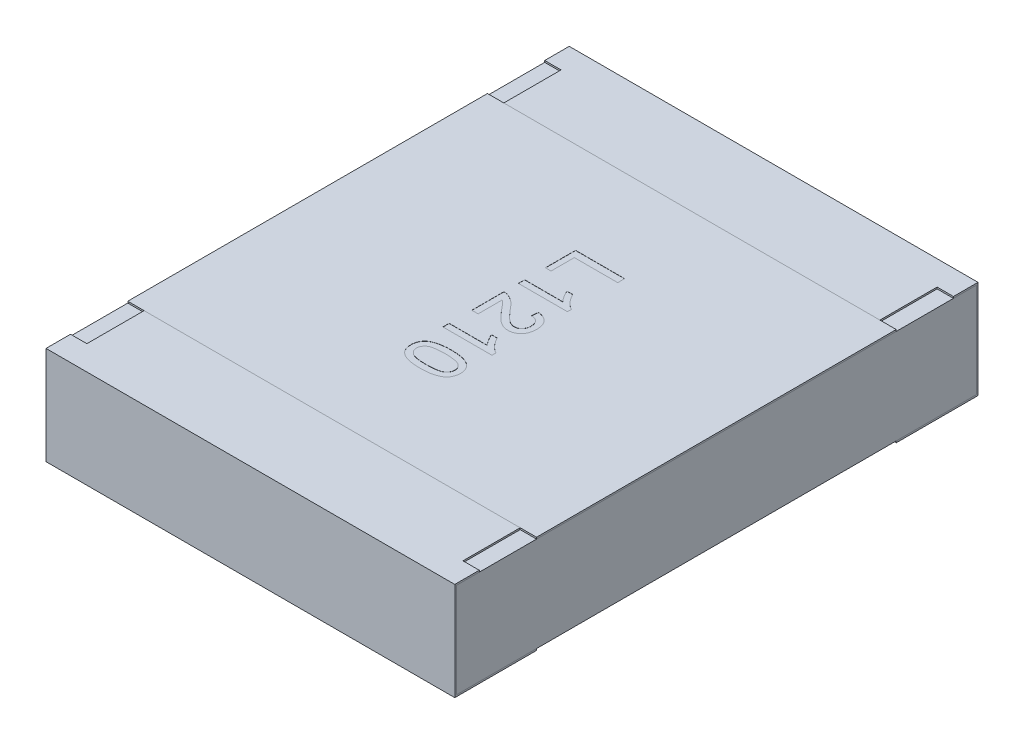
from build123d import *

# Parameters (mm, degrees)
BOSS_EXTRUDE2_DEPTH   = 1.25
BOSS_EXTRUDE2_2_DEPTH = 1.25
BOSS_EXTRUDE3_START   = -1.25
SKETCH5_W             = 3.18
SKETCH5_H             = 0.58
BOSS_EXTRUDE3_DEPTH   = 2.5
SKETCH6_W             = 0.1
SKETCH6_H             = 0.35
CUT_EXTRUDE1_DEPTH    = 0.01
SKETCH7_W             = 2.5
SKETCH7_H             = 2.2
BOSS_EXTRUDE4_DEPTH   = 0.01
TEXT1210_DEPTH        = 0.001


with BuildPart() as part:
    # Sketch4 → Boss-Extrude2 (new body, symmetric)
    with BuildSketch(Plane(origin=(0, 0, 0), x_dir=(0, 0, -1), z_dir=(1, 0, 0))):
        Polygon((-1.6, 0.3), (-1.6, -0.3), (-1.1, -0.3), (-1.1, -0.29), (-1.59, -0.29), (-1.59, 0.29), (-1.1, 0.29), (-1.1, 0.3), align=None)
    extrude(amount=BOSS_EXTRUDE2_DEPTH, both=True)


with BuildPart() as body_2:
    # Sketch4 → Boss-Extrude2 2 (new body, symmetric)
    with BuildSketch(Plane(origin=(0, 0, 0), x_dir=(0, 0, -1), z_dir=(1, 0, 0))):
        Polygon((1.1, 0.3), (1.6, 0.3), (1.6, -0.3), (1.1, -0.3), (1.1, -0.29), (1.59, -0.29), (1.59, 0.29), (1.1, 0.29), align=None)
    extrude(amount=BOSS_EXTRUDE2_2_DEPTH, both=True)


with BuildPart() as body_3:
    # Sketch5 → Boss-Extrude3 (new body)
    with BuildSketch(Plane(origin=(0, 0, 0), x_dir=(0, 0, -1), z_dir=(1, 0, 0)).offset(BOSS_EXTRUDE3_START)):
        Rectangle(SKETCH5_W, SKETCH5_H)
    extrude(amount=BOSS_EXTRUDE3_DEPTH)


with BuildPart() as cut_extrude1_tool:
    # Sketch6 → Cut-Extrude1 (new body)
    with BuildSketch(Plane(origin=(0, 0.3, 0), x_dir=(1, 0, 0), z_dir=(0, 1, 0))):
        with Locations((-1.2, 1.275)):
            Rectangle(SKETCH6_W, SKETCH6_H)
        with Locations((1.2, 1.275)):
            Rectangle(SKETCH6_W, SKETCH6_H)
        with Locations((1.2, -1.275)):
            Rectangle(SKETCH6_W, SKETCH6_H)
        with Locations((-1.2, -1.275)):
            Rectangle(SKETCH6_W, SKETCH6_H)
    extrude(amount=-CUT_EXTRUDE1_DEPTH)


with BuildPart() as part_1:
    add(part.part)

    # Cut-Extrude1: cut by cut_extrude1_tool
    add(cut_extrude1_tool.part, mode=Mode.SUBTRACT)


with BuildPart() as body_2_1:
    add(body_2.part)

    # Cut-Extrude1: cut by cut_extrude1_tool
    add(cut_extrude1_tool.part, mode=Mode.SUBTRACT)


with BuildPart() as body_4:
    # Sketch7 → Boss-Extrude4 (new body)
    with BuildSketch(Plane(origin=(0, 0.29, 0), x_dir=(1, 0, 0), z_dir=(0, 1, 0))):
        Rectangle(SKETCH7_W, SKETCH7_H)
    extrude(amount=BOSS_EXTRUDE4_DEPTH)

    # Sketch13 → TEXT1210 (cut)
    with BuildSketch(Plane(origin=(0, 0.3, 0), x_dir=(1, 0, 0), z_dir=(0, 1, 0))):
        Polygon((-0.15, 0.53890045), (0.15, 0.53890045), (0.15, 0.496592758), (-0.115384615, 0.496592758), (-0.115384615, 0.354285066), (-0.15, 0.354285066), align=None)
        with BuildLine():
            Line((-0.15, 0.18890045), (-0.15, 0.227361989))
            Line((-0.15, 0.227361989), (0.083774038, 0.227361989))
            add(Edge.make_bspline(
                [(0.083774038, 0.227361989), (0.081638509, 0.229576734), (0.077200045, 0.234179841), (0.070914564, 0.241958301), (0.064571645, 0.250638154), (0.058389404, 0.260075408), (0.052683492, 0.269769346), (0.047476916, 0.27910891), (0.043093554, 0.287963651), (0.040694469, 0.293794722), (0.039543269, 0.296592758)],
                knots=[0, 0, 0, 0, 9.226e-06, 1.9175e-05, 2.9969e-05, 4.147e-05, 5.3003e-05, 6.3709e-05, 7.3546e-05, 8.262e-05, 8.262e-05, 8.262e-05, 8.262e-05], degree=3))
            Line((0.039543269, 0.296592758), (0.075, 0.296592758))
            add(Edge.make_bspline(
                [(0.075, 0.296592758), (0.077475162, 0.291786638), (0.082353558, 0.282314059), (0.09077922, 0.268931354), (0.099912985, 0.256437159), (0.10975283, 0.245038303), (0.119810917, 0.234819955), (0.129959923, 0.226208805), (0.139827828, 0.219003542), (0.146709597, 0.215388526), (0.15, 0.213660066)],
                knots=[0, 0, 0, 0, 1.6212e-05, 3.1953e-05, 4.7386e-05, 6.26e-05, 7.7091e-05, 9.0349e-05, 0.000102505, 0.000113642, 0.000113642, 0.000113642, 0.000113642], degree=3))
            Line((0.15, 0.213660066), (0.15, 0.18890045))
            Line((0.15, 0.18890045), (-0.15, 0.18890045))
        make_face()
        with BuildLine():
            Line((-0.111538462, -0.095714934), (-0.15, -0.095714934))
            Line((-0.15, -0.095714934), (-0.15, 0.100438912))
            add(Edge.make_bspline(
                [(-0.15, 0.100438912), (-0.147714123, 0.100442928), (-0.14315003, 0.100450946), (-0.136400026, 0.099678628), (-0.129739566, 0.098469023), (-0.125468478, 0.097101323), (-0.123317308, 0.096412469)],
                knots=[0, 0, 0, 0, 6.852e-06, 1.3681e-05, 2.0352e-05, 2.7121e-05, 2.7121e-05, 2.7121e-05, 2.7121e-05], degree=3))
            add(Edge.make_bspline(
                [(-0.123317308, 0.096412469), (-0.119803316, 0.095138453), (-0.112648251, 0.092544345), (-0.102300861, 0.087308751), (-0.092077121, 0.081048211), (-0.083693742, 0.075056739), (-0.077044802, 0.069538585), (-0.071780052, 0.064988128), (-0.066458477, 0.059862129), (-0.06098519, 0.054254035), (-0.055359875, 0.048197879), (-0.049556317, 0.041693897), (-0.043684824, 0.034662817), (-0.039792869, 0.02975449), (-0.037800481, 0.027241796)],
                knots=[0, 0, 0, 0, 1.1205e-05, 2.2816e-05, 3.4709e-05, 4.7152e-05, 5.3684e-05, 6.0627e-05, 6.8023e-05, 7.5842e-05, 8.4134e-05, 9.2818e-05, 0.00010199, 0.00011161, 0.00011161, 0.00011161, 0.00011161], degree=3))
            add(Edge.make_bspline(
                [(-0.037800481, 0.027241796), (-0.034551471, 0.023381665), (-0.028295295, 0.015948736), (-0.019011711, 0.005452276), (-0.010391377, -0.004134531), (-0.002283205, -0.012659028), (0.005234162, -0.020190934), (0.012143692, -0.026747935), (0.018423822, -0.03238645), (0.024301865, -0.037037644), (0.029852373, -0.040961998), (0.035266551, -0.044287542), (0.040638972, -0.047058942), (0.045952637, -0.049367147), (0.05123027, -0.051192741), (0.056487246, -0.052437143), (0.061671403, -0.053281053), (0.065120999, -0.053365487), (0.066826923, -0.053407242)],
                knots=[0, 0, 0, 0, 1.5136e-05, 2.9145e-05, 4.2036e-05, 5.3811e-05, 6.4435e-05, 7.3957e-05, 8.2386e-05, 8.9745e-05, 9.643e-05, 0.000102769, 0.00010879, 0.00011455, 0.000120137, 0.000125516, 0.000130743, 0.000135857, 0.000135857, 0.000135857, 0.000135857], degree=3))
            add(Edge.make_bspline(
                [(0.066826923, -0.053407242), (0.068512943, -0.053365482), (0.071820821, -0.053283551), (0.076661881, -0.052506195), (0.081323937, -0.051424053), (0.085723062, -0.049674559), (0.089989535, -0.047592135), (0.093988521, -0.044920918), (0.097819766, -0.041830895), (0.101381944, -0.038292978), (0.104724786, -0.034429128), (0.107500012, -0.030110376), (0.110020859, -0.025610863), (0.111988045, -0.020781877), (0.113504097, -0.015666428), (0.114560258, -0.01027272), (0.115243078, -0.004586351), (0.115336721, -0.000704927), (0.115384615, 0.001280258)],
                knots=[0, 0, 0, 0, 5.054e-06, 9.915e-06, 1.4681e-05, 1.938e-05, 2.4083e-05, 2.89e-05, 3.3772e-05, 3.8829e-05, 4.3946e-05, 4.9063e-05, 5.4199e-05, 5.94e-05, 6.4667e-05, 7.0183e-05, 7.587e-05, 8.1825e-05, 8.1825e-05, 8.1825e-05, 8.1825e-05], degree=3))
            add(Edge.make_bspline(
                [(0.115384615, 0.001280258), (0.115336639, 0.003365522), (0.115242746, 0.007446536), (0.114561705, 0.013412531), (0.113515033, 0.019073785), (0.111941815, 0.024410106), (0.109882187, 0.029410823), (0.10742732, 0.034111385), (0.104518024, 0.03849382), (0.101139001, 0.042487997), (0.097458268, 0.046187848), (0.093296561, 0.049313409), (0.088872885, 0.052045577), (0.084046797, 0.05420091), (0.078924308, 0.055958652), (0.073429376, 0.057227398), (0.067585566, 0.057920825), (0.063583419, 0.05806007), (0.061538462, 0.058131219)],
                knots=[0, 0, 0, 0, 6.255e-06, 1.2241e-05, 1.7992e-05, 2.3507e-05, 2.8897e-05, 3.4193e-05, 3.9393e-05, 4.4641e-05, 4.9868e-05, 5.5012e-05, 6.0217e-05, 6.5434e-05, 7.0832e-05, 7.6444e-05, 8.2318e-05, 8.8455e-05, 8.8455e-05, 8.8455e-05, 8.8455e-05], degree=3))
            Line((0.061538462, 0.058131219), (0.065384615, 0.096592758))
            add(Edge.make_bspline(
                [(0.065384615, 0.096592758), (0.068736662, 0.096199283), (0.07525778, 0.095433812), (0.084702032, 0.093526357), (0.093489714, 0.090851287), (0.101734943, 0.087640776), (0.109336857, 0.083645414), (0.116323186, 0.079013557), (0.122725854, 0.073748815), (0.12839596, 0.067759508), (0.133571363, 0.061274876), (0.137925688, 0.054134056), (0.141698648, 0.046502706), (0.144749435, 0.038326511), (0.147087025, 0.029608682), (0.148758415, 0.020362795), (0.149789925, 0.010578384), (0.149928976, 0.00386696), (0.15, 0.000438912)],
                knots=[0, 0, 0, 0, 1.0123e-05, 1.9693e-05, 2.8857e-05, 3.7651e-05, 4.6199e-05, 5.4566e-05, 6.276e-05, 7.1006e-05, 7.9266e-05, 8.7604e-05, 9.6043e-05, 0.000104772, 0.000113738, 0.000123085, 0.000132934, 0.000143217, 0.000143217, 0.000143217, 0.000143217], degree=3))
            add(Edge.make_bspline(
                [(0.15, 0.000438912), (0.149940576, -0.003030142), (0.149824817, -0.00978788), (0.148641062, -0.019635171), (0.146795931, -0.028925684), (0.144229333, -0.037696602), (0.140839664, -0.045901328), (0.136757117, -0.053567953), (0.131911514, -0.0606722), (0.126324053, -0.067117627), (0.120221623, -0.072930045), (0.113705953, -0.078016298), (0.106829733, -0.082292372), (0.099612825, -0.085829272), (0.092008541, -0.088537508), (0.084045391, -0.090422257), (0.075742745, -0.091708806), (0.070077161, -0.091814747), (0.0671875, -0.091868781)],
                knots=[0, 0, 0, 0, 1.0403e-05, 2.0265e-05, 2.9705e-05, 3.8794e-05, 4.7633e-05, 5.6291e-05, 6.4808e-05, 7.3373e-05, 8.1833e-05, 9.0055e-05, 9.8126e-05, 0.000106082, 0.000114122, 0.000122285, 0.000130605, 0.000139266, 0.000139266, 0.000139266, 0.000139266], degree=3))
            add(Edge.make_bspline(
                [(0.0671875, -0.091868781), (0.064218398, -0.091787667), (0.05827364, -0.091625261), (0.049399233, -0.090309986), (0.040594357, -0.08819279), (0.03178904, -0.08525502), (0.02297561, -0.081166575), (0.013942435, -0.076131331), (0.004756402, -0.069837959), (-0.003111225, -0.063869709), (-0.009660413, -0.058250445), (-0.015062592, -0.053269642), (-0.020824791, -0.047508563), (-0.027059821, -0.041120412), (-0.033675497, -0.033974347), (-0.04077151, -0.026200588), (-0.048197577, -0.017644735), (-0.053269547, -0.011704156), (-0.055889423, -0.008635607)],
                knots=[0, 0, 0, 0, 8.904e-06, 1.7828e-05, 2.6851e-05, 3.6049e-05, 4.5623e-05, 5.5954e-05, 6.7039e-05, 7.8998e-05, 8.5562e-05, 9.292e-05, 0.000101036, 0.000110004, 0.000119698, 0.000130249, 0.000141579, 0.000153683, 0.000153683, 0.000153683, 0.000153683], degree=3))
            add(Edge.make_bspline(
                [(-0.055889423, -0.008635607), (-0.058028577, -0.00600791), (-0.062107615, -0.000997295), (-0.068021764, 0.006130704), (-0.073442596, 0.012517194), (-0.07820298, 0.01830303), (-0.082492694, 0.023292168), (-0.086224809, 0.027591619), (-0.089451821, 0.031158691), (-0.094402484, 0.036596509), (-0.10140021, 0.043536178), (-0.108253196, 0.048608326), (-0.111538462, 0.051039873)],
                knots=[0, 0, 0, 0, 1.0165e-05, 1.9383e-05, 2.7786e-05, 3.5295e-05, 4.1859e-05, 4.7524e-05, 5.2375e-05, 5.6288e-05, 6.9591e-05, 8.184e-05, 8.184e-05, 8.184e-05, 8.184e-05], degree=3))
            Line((-0.111538462, 0.051039873), (-0.111538462, -0.095714934))
        make_face()
        with BuildLine():
            Line((-0.15, -0.272638011), (-0.15, -0.234176473))
            Line((-0.15, -0.234176473), (0.083774038, -0.234176473))
            add(Edge.make_bspline(
                [(0.083774038, -0.234176473), (0.081638509, -0.231961727), (0.077200045, -0.227358621), (0.070914564, -0.21958016), (0.064571645, -0.210900308), (0.058389404, -0.201463054), (0.052683492, -0.191769115), (0.047476916, -0.182429552), (0.043093554, -0.17357481), (0.040694469, -0.167743739), (0.039543269, -0.164945704)],
                knots=[0, 0, 0, 0, 9.226e-06, 1.9175e-05, 2.9969e-05, 4.147e-05, 5.3003e-05, 6.3709e-05, 7.3546e-05, 8.262e-05, 8.262e-05, 8.262e-05, 8.262e-05], degree=3))
            Line((0.039543269, -0.164945704), (0.075, -0.164945704))
            add(Edge.make_bspline(
                [(0.075, -0.164945704), (0.077475162, -0.169751824), (0.082353558, -0.179224402), (0.09077922, -0.192607107), (0.099912985, -0.205101302), (0.10975283, -0.216500158), (0.119810917, -0.226718506), (0.129959923, -0.235329657), (0.139827828, -0.242534919), (0.146709597, -0.246149936), (0.15, -0.247878396)],
                knots=[0, 0, 0, 0, 1.6212e-05, 3.1953e-05, 4.7386e-05, 6.26e-05, 7.7091e-05, 9.0349e-05, 0.000102505, 0.000113642, 0.000113642, 0.000113642, 0.000113642], degree=3))
            Line((0.15, -0.247878396), (0.15, -0.272638011))
            Line((0.15, -0.272638011), (-0.15, -0.272638011))
        make_face()
        with BuildLine():
            add(Edge.make_bspline(
                [(-0.002043269, -0.368791857), (0.002244006, -0.368830608), (0.010640973, -0.368906503), (0.022927245, -0.369377254), (0.034595007, -0.37019915), (0.045634132, -0.371426007), (0.05606952, -0.372878857), (0.065886336, -0.374767497), (0.075106414, -0.376892738), (0.083720798, -0.379441782), (0.091801288, -0.382245278), (0.099342803, -0.385415635), (0.106300734, -0.389014065), (0.112864039, -0.392716086), (0.118725274, -0.397026184), (0.12425569, -0.401397143), (0.129139599, -0.406276003), (0.133536862, -0.411430723), (0.137415967, -0.416946734), (0.140763485, -0.422792352), (0.143719015, -0.42894575), (0.145943958, -0.435524024), (0.147757752, -0.44239066), (0.149092003, -0.4495985), (0.149878588, -0.45715549), (0.149959072, -0.46231963), (0.15, -0.464945704)],
                knots=[0, 0, 0, 0, 1.2862e-05, 2.5191e-05, 3.688e-05, 4.7943e-05, 5.8507e-05, 6.8478e-05, 7.7924e-05, 8.6881e-05, 9.5415e-05, 0.000103574, 0.000111395, 0.000118909, 0.000126147, 0.000133195, 0.000140037, 0.000146816, 0.000153502, 0.000160233, 0.000167008, 0.000173945, 0.000181029, 0.000188302, 0.000195914, 0.00020379, 0.00020379, 0.00020379, 0.00020379], degree=3))
            add(Edge.make_bspline(
                [(0.15, -0.464945704), (0.149886629, -0.468798426), (0.149663908, -0.476367254), (0.147850494, -0.487418957), (0.144740696, -0.49783), (0.140578188, -0.507598756), (0.135193656, -0.516513994), (0.128816305, -0.524574198), (0.121179131, -0.531453701), (0.11253276, -0.537379751), (0.102860028, -0.542461339), (0.092252026, -0.547007027), (0.080663785, -0.55108266), (0.070320072, -0.554065846), (0.061375886, -0.556157324), (0.053985027, -0.557430675), (0.046034731, -0.558606346), (0.03750596, -0.559439678), (0.028438575, -0.560287661), (0.018793038, -0.560706321), (0.008575899, -0.561025819), (0.001562812, -0.561074512), (-0.002043269, -0.56109955)],
                knots=[0, 0, 0, 0, 1.1554e-05, 2.2698e-05, 3.348e-05, 4.4085e-05, 5.4464e-05, 6.4638e-05, 7.4805e-05, 8.5173e-05, 9.6008e-05, 0.000107529, 0.00011977, 0.000132837, 0.000139806, 0.000147315, 0.000155329, 0.00016391, 0.000173019, 0.000182646, 0.000192867, 0.000203685, 0.000203685, 0.000203685, 0.000203685], degree=3))
            add(Edge.make_bspline(
                [(-0.002043269, -0.56109955), (-0.00631044, -0.561060292), (-0.014647199, -0.560983595), (-0.026834487, -0.560522423), (-0.03841587, -0.559661687), (-0.049405471, -0.558552503), (-0.059813481, -0.557059128), (-0.069614428, -0.55519258), (-0.078820333, -0.553036715), (-0.087440482, -0.550597058), (-0.095486737, -0.547758694), (-0.102997606, -0.544557395), (-0.110046684, -0.541124657), (-0.116502689, -0.537230998), (-0.122472492, -0.533084021), (-0.127974887, -0.528644981), (-0.132931669, -0.523821932), (-0.137314485, -0.518619096), (-0.141263346, -0.513142462), (-0.144641302, -0.507281652), (-0.147459366, -0.501050378), (-0.149814671, -0.494504175), (-0.151604655, -0.487599592), (-0.15293367, -0.480372606), (-0.153727476, -0.472776068), (-0.153806049, -0.467591837), (-0.153846154, -0.464945704)],
                knots=[0, 0, 0, 0, 1.2802e-05, 2.5011e-05, 3.658e-05, 4.7637e-05, 5.8141e-05, 6.8112e-05, 7.7558e-05, 8.6498e-05, 9.4975e-05, 0.000103135, 0.000110983, 0.000118475, 0.000125727, 0.000132776, 0.000139661, 0.00014644, 0.00015316, 0.000159891, 0.000166695, 0.000173652, 0.000180737, 0.000188068, 0.000195681, 0.000203617, 0.000203617, 0.000203617, 0.000203617], degree=3))
            add(Edge.make_bspline(
                [(-0.153846154, -0.464945704), (-0.153747192, -0.461476394), (-0.153554242, -0.454712195), (-0.152243272, -0.44483358), (-0.149935902, -0.435561974), (-0.146841394, -0.426819175), (-0.142702311, -0.418703454), (-0.137666308, -0.411176063), (-0.131850554, -0.404085743), (-0.127262057, -0.400004124), (-0.124939904, -0.397938492)],
                knots=[0, 0, 0, 0, 1.0408e-05, 2.0292e-05, 2.9825e-05, 3.9025e-05, 4.8056e-05, 5.7073e-05, 6.616e-05, 7.5471e-05, 7.5471e-05, 7.5471e-05, 7.5471e-05], degree=3))
            add(Edge.make_bspline(
                [(-0.124939904, -0.397938492), (-0.121510195, -0.395560902), (-0.11443799, -0.39065821), (-0.102379223, -0.384920033), (-0.089104214, -0.379801478), (-0.074352508, -0.375784351), (-0.058241513, -0.372637939), (-0.040739616, -0.370365444), (-0.021854376, -0.369079436), (-0.008796046, -0.368889881), (-0.002043269, -0.368791857)],
                knots=[0, 0, 0, 0, 1.2501e-05, 2.5778e-05, 3.993e-05, 5.5152e-05, 7.157e-05, 8.9147e-05, 0.000108063, 0.000128321, 0.000128321, 0.000128321, 0.000128321], degree=3))
        make_face()
        with BuildLine():
            add(Edge.make_bspline(
                [(-0.001923077, -0.407253396), (-0.007693168, -0.407291585), (-0.018738399, -0.407364688), (-0.034518417, -0.408128433), (-0.048754147, -0.40944319), (-0.061425879, -0.411181383), (-0.072550754, -0.413476503), (-0.082100422, -0.416358297), (-0.090189501, -0.419606764), (-0.096717734, -0.423626681), (-0.102039196, -0.428028046), (-0.106615825, -0.432572155), (-0.110505855, -0.437365914), (-0.113749347, -0.442378045), (-0.116205105, -0.447686315), (-0.117985045, -0.453232679), (-0.119009373, -0.459018343), (-0.119156549, -0.462958644), (-0.119230769, -0.464945704)],
                knots=[0, 0, 0, 0, 1.7309e-05, 3.3134e-05, 4.7378e-05, 6.0186e-05, 7.1489e-05, 8.1413e-05, 9.0085e-05, 9.7558e-05, 0.000104306, 0.000110765, 0.000116876, 0.000122794, 0.000128628, 0.000134368, 0.000140227, 0.000146187, 0.000146187, 0.000146187, 0.000146187], degree=3))
            add(Edge.make_bspline(
                [(-0.119230769, -0.464945704), (-0.119154928, -0.466932266), (-0.119004535, -0.47087158), (-0.118002795, -0.476670613), (-0.116131225, -0.482195397), (-0.11368414, -0.487495752), (-0.110514577, -0.492544313), (-0.106609854, -0.497314529), (-0.102035942, -0.501882574), (-0.096652628, -0.506264169), (-0.090094213, -0.510253459), (-0.082011723, -0.513562864), (-0.072445331, -0.516399747), (-0.061326124, -0.51870746), (-0.048674427, -0.520452824), (-0.03447818, -0.521759631), (-0.018718466, -0.522528488), (-0.007693194, -0.522600384), (-0.001923077, -0.522638011)],
                knots=[0, 0, 0, 0, 5.96e-06, 1.1819e-05, 1.7578e-05, 2.3412e-05, 2.9298e-05, 3.5408e-05, 4.1867e-05, 4.8662e-05, 5.6186e-05, 6.4803e-05, 7.4784e-05, 8.6088e-05, 9.8836e-05, 0.00011308, 0.000128845, 0.000146154, 0.000146154, 0.000146154, 0.000146154], degree=3))
            add(Edge.make_bspline(
                [(-0.001923077, -0.522638011), (0.003726983, -0.522601589), (0.014552285, -0.522531806), (0.030028294, -0.521743114), (0.044025103, -0.520507191), (0.056555506, -0.518816554), (0.067606248, -0.516569984), (0.077199767, -0.513844336), (0.085318952, -0.510598965), (0.09203502, -0.506732082), (0.097578912, -0.502444607), (0.102284051, -0.497889274), (0.106407321, -0.493154239), (0.109635927, -0.487968915), (0.11228385, -0.482553737), (0.114056455, -0.476792621), (0.1151941, -0.470759955), (0.115320181, -0.466633736), (0.115384615, -0.464525031)],
                knots=[0, 0, 0, 0, 1.6949e-05, 3.2473e-05, 4.6473e-05, 5.9094e-05, 7.0385e-05, 8.0274e-05, 8.8979e-05, 9.6545e-05, 0.000103444, 0.000109947, 0.000116172, 0.000122224, 0.000128218, 0.000134205, 0.000140252, 0.000146573, 0.000146573, 0.000146573, 0.000146573], degree=3))
            add(Edge.make_bspline(
                [(0.115384615, -0.464525031), (0.115332466, -0.462538095), (0.115229635, -0.458620114), (0.114248109, -0.452883676), (0.112606778, -0.447447321), (0.110383437, -0.442248766), (0.107391258, -0.43741779), (0.103897677, -0.432762809), (0.099641138, -0.428501844), (0.096459016, -0.425934224), (0.094831731, -0.424621184)],
                knots=[0, 0, 0, 0, 5.957e-06, 1.1747e-05, 1.7393e-05, 2.2965e-05, 2.8654e-05, 3.4399e-05, 4.0391e-05, 4.6662e-05, 4.6662e-05, 4.6662e-05, 4.6662e-05], degree=3))
            add(Edge.make_bspline(
                [(0.094831731, -0.424621184), (0.092441753, -0.423191685), (0.087394622, -0.420172884), (0.078622501, -0.416795022), (0.068597636, -0.413811151), (0.057165788, -0.411354436), (0.044346567, -0.409577176), (0.03015486, -0.408174097), (0.014570853, -0.40744525), (0.003726591, -0.407319112), (-0.001923077, -0.407253396)],
                knots=[0, 0, 0, 0, 8.341e-06, 1.7615e-05, 2.8091e-05, 3.9714e-05, 5.2649e-05, 6.6899e-05, 8.2483e-05, 9.9433e-05, 9.9433e-05, 9.9433e-05, 9.9433e-05], degree=3))
        make_face(mode=Mode.SUBTRACT)
    extrude(amount=-TEXT1210_DEPTH, mode=Mode.SUBTRACT)


solid = Compound([body_3.part, part_1.part, body_2_1.part, body_4.part])
